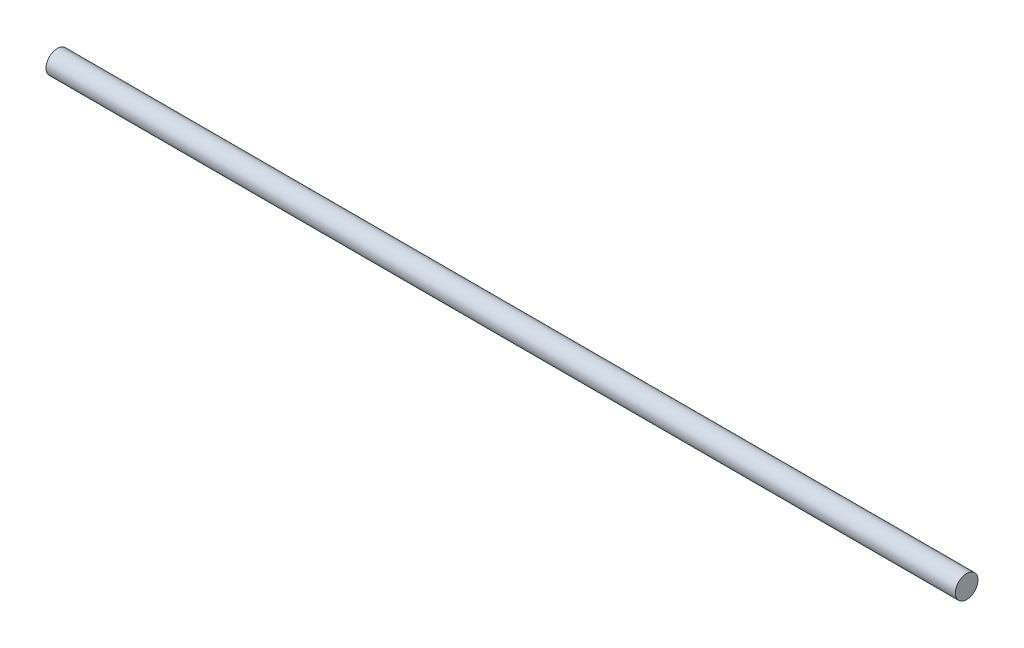
from build123d import *

# Parameters (mm, degrees)
SKETCH1_R           = 24.95
BOSS_EXTRUDE1_DEPTH = 2000


with BuildPart() as part:
    # Sketch1 → Boss-Extrude1 (new body)
    with BuildSketch(Plane(origin=(0, 0, 0), x_dir=(0, 0, -1), z_dir=(1, 0, 0))):
        Circle(SKETCH1_R)
    extrude(amount=BOSS_EXTRUDE1_DEPTH)


solid = part.part
